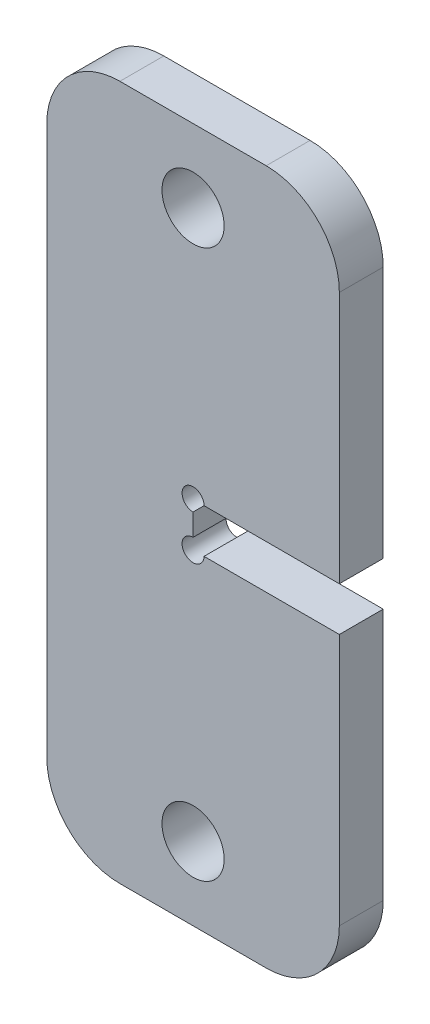
from build123d import *

# Parameters (mm, degrees)
SKETCH1_R           = 4.25
BOSS_EXTRUDE1_DEPTH = 6
SKETCH3_R           = 1.5
CUT_EXTRUDE1_DEPTH  = 7


with BuildPart() as part:
    # Sketch1 → Boss-Extrude1 (new body)
    with BuildSketch(Plane.XY):
        with BuildLine():
            Line((711, 350.5), (711, 385))
            ThreePointArc((711, 385), (708.071067812, 392.071067812), (701, 395))
            Line((701, 395), (681, 395))
            ThreePointArc((681, 395), (673.928932188, 392.071067812), (671, 385))
            Line((671, 385), (671, 310))
            ThreePointArc((671, 310), (673.928932188, 302.928932188), (681, 300))
            Line((681, 300), (701, 300))
            ThreePointArc((701, 300), (708.071067812, 302.928932188), (711, 310))
            Line((711, 310), (711, 344.5))
            Line((711, 344.5), (691, 344.5))
            Line((691, 344.5), (691, 350.5))
            Line((691, 350.5), (711, 350.5))
        make_face()
        with Locations((691, 310)):
            Circle(SKETCH1_R, mode=Mode.SUBTRACT)
        with Locations((691, 385)):
            Circle(SKETCH1_R, mode=Mode.SUBTRACT)
    extrude(amount=BOSS_EXTRUDE1_DEPTH)

    # Sketch3 → Cut-Extrude1 (cut, through all)
    with BuildSketch(Plane.XY.offset(6)):
        with Locations((691, 350.5)):
            Circle(SKETCH3_R)
        with Locations((691, 344.5)):
            Circle(SKETCH3_R)
    extrude(amount=-CUT_EXTRUDE1_DEPTH, mode=Mode.SUBTRACT)


solid = part.part
